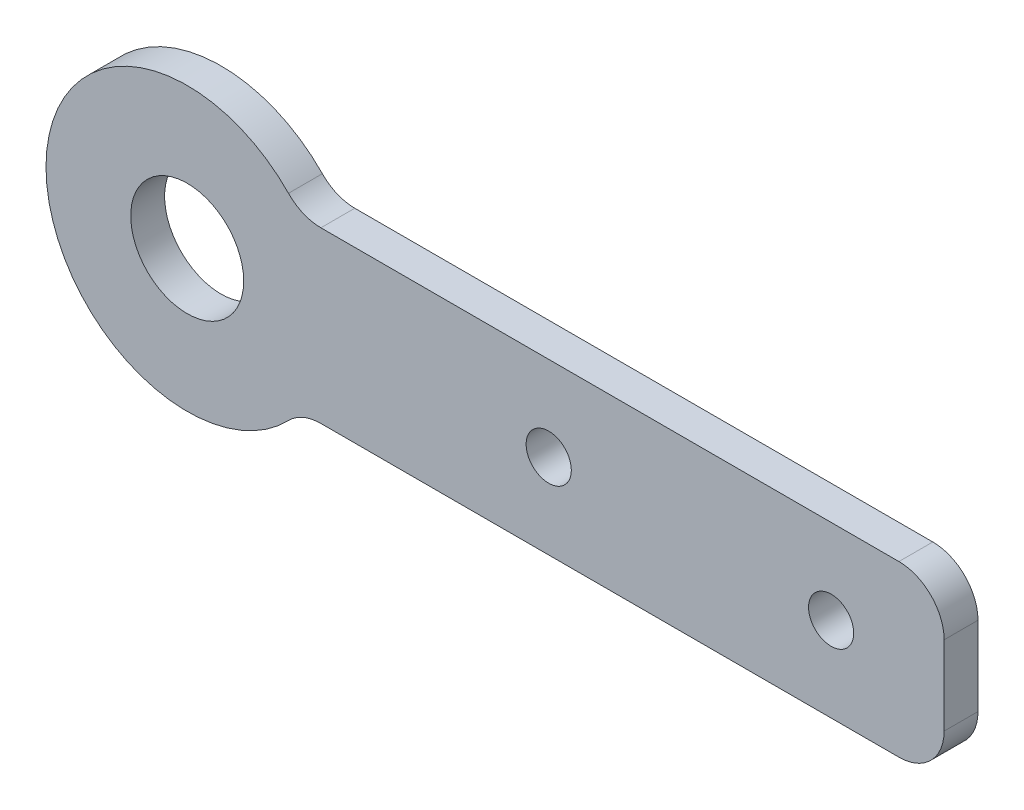
from build123d import *

# Parameters (mm, degrees)
SKETCH1_R           = 5
SKETCH1_R_2         = 2
BOSS_EXTRUDE1_DEPTH = 3
FILLET2_R           = 4


with BuildPart() as part:
    # Sketch1 → Boss-Extrude1 (new body)
    with BuildSketch(Plane.XY):
        with BuildLine():
            Line((20, 0), (77, 0))
            Line((77, 0), (77, 15))
            Line((77, 15), (20, 15))
            ThreePointArc((20, 15), (-2.5, 7.5), (20, 0))
        make_face()
        with Locations((10, 7.5)):
            Circle(SKETCH1_R, mode=Mode.SUBTRACT)
        with Locations((67, 7.5)):
            Circle(SKETCH1_R_2, mode=Mode.SUBTRACT)
        with Locations((42, 7.5)):
            Circle(SKETCH1_R_2, mode=Mode.SUBTRACT)
    extrude(amount=BOSS_EXTRUDE1_DEPTH)

    # Fillet2
    fillet2_edges = [part.edges().sort_by_distance(p)[0] for p in [
        (20, 15, 1.5),
        (77, 15, 1.5),
        (77, 0, 1.5),
        (20, 0, 1.5),
    ]]
    fillet(fillet2_edges, radius=FILLET2_R)


solid = part.part
